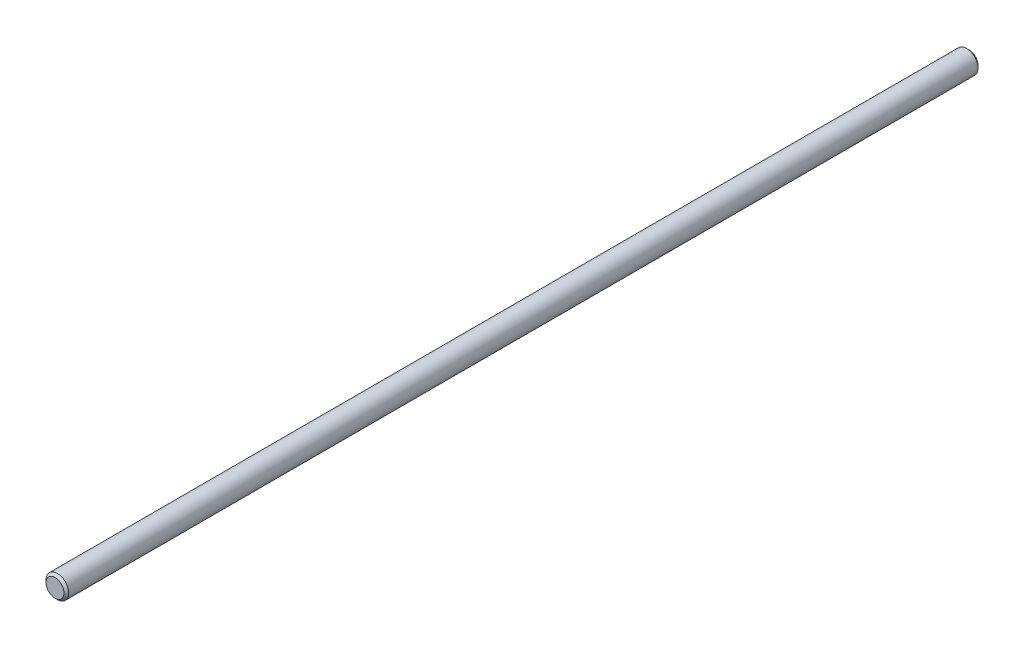
from build123d import *

# Parameters (mm, degrees)
SKETCH1_R           = 4.826
BOSS_EXTRUDE1_DEPTH = 194.5
CHAMFER1_SIZE       = 1


with BuildPart() as part:
    # Sketch1 → Boss-Extrude1 (new body, symmetric)
    with BuildSketch(Plane.XY):
        Circle(SKETCH1_R)
    extrude(amount=BOSS_EXTRUDE1_DEPTH, both=True)

    # Chamfer1
    chamfer1_edges = [part.edges().sort_by_distance(p)[0] for p in [
        (-4.826, 0, -194.5),
        (-4.826, 0, 194.5),
    ]]
    chamfer(chamfer1_edges, length=CHAMFER1_SIZE)


solid = part.part
